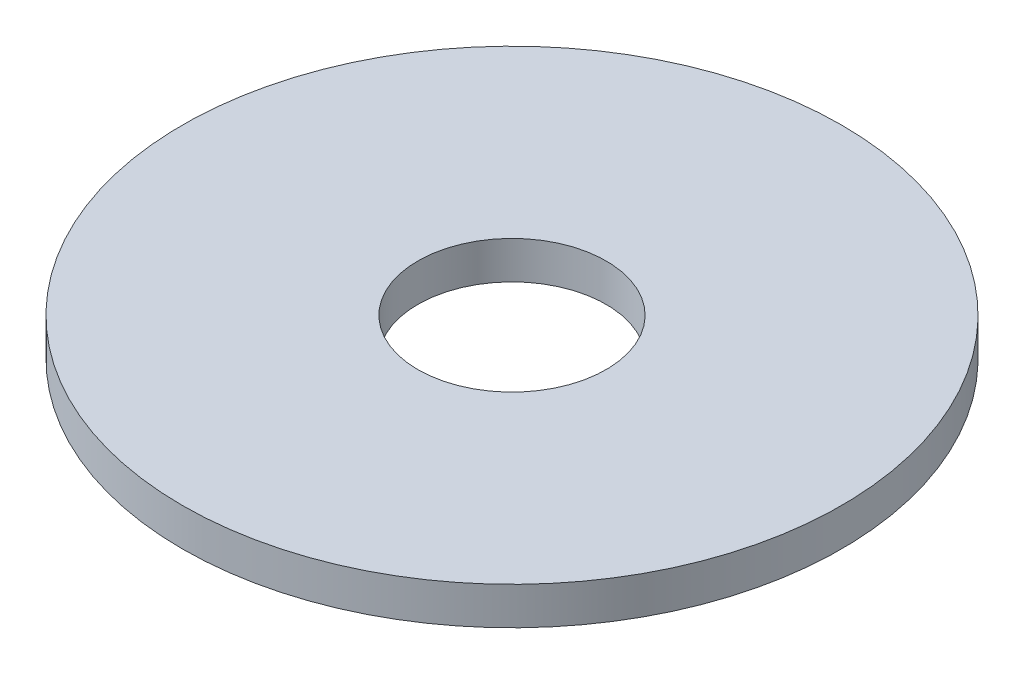
from build123d import *

# Parameters (mm, degrees)
SKETCH1_R           = 35
BOSS_EXTRUDE1_DEPTH = 4
SKETCH2_R           = 10
CUT_EXTRUDE1_DEPTH  = 10


with BuildPart() as part:
    # Sketch1 → Boss-Extrude1 (new body)
    with BuildSketch(Plane(origin=(0, 0, 0), x_dir=(1, 0, 0), z_dir=(0, 1, 0))):
        Circle(SKETCH1_R)
    extrude(amount=BOSS_EXTRUDE1_DEPTH)

    # Sketch2 → Cut-Extrude1 (cut)
    with BuildSketch(Plane(origin=(0, 4, 0), x_dir=(1, 0, 0), z_dir=(0, 1, 0))):
        Circle(SKETCH2_R)
    extrude(amount=-CUT_EXTRUDE1_DEPTH, mode=Mode.SUBTRACT)


solid = part.part
